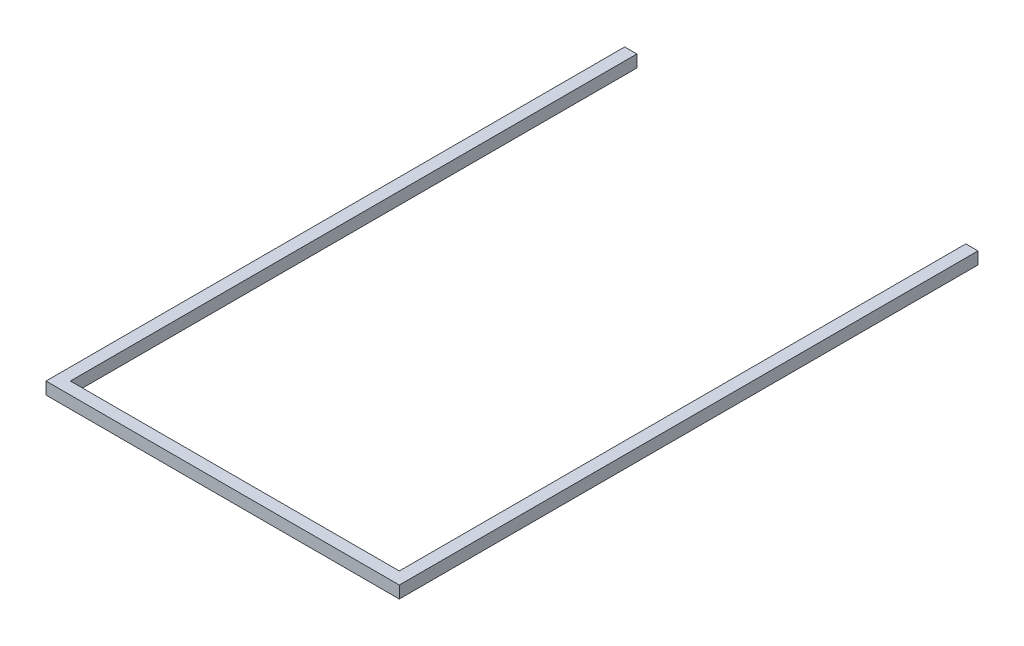
from build123d import *

# Parameters (mm, degrees)
BOSS_EXTRUDE1_DEPTH = 20


with BuildPart() as part:
    # Sketch1 → Boss-Extrude1 (new body)
    with BuildSketch(Plane(origin=(0, 0, 0), x_dir=(1, 0, 0), z_dir=(0, 1, 0))):
        Polygon((-81.144259733, 891.78781367), (-81.144259733, -58.21218633), (498.855740267, -58.21218633), (498.855740267, 891.78781367), (478.855740267, 891.78781367), (478.855740267, -38.21218633), (-61.144259733, -38.21218633), (-61.144259733, 891.78781367), align=None)
    extrude(amount=BOSS_EXTRUDE1_DEPTH)


solid = part.part
